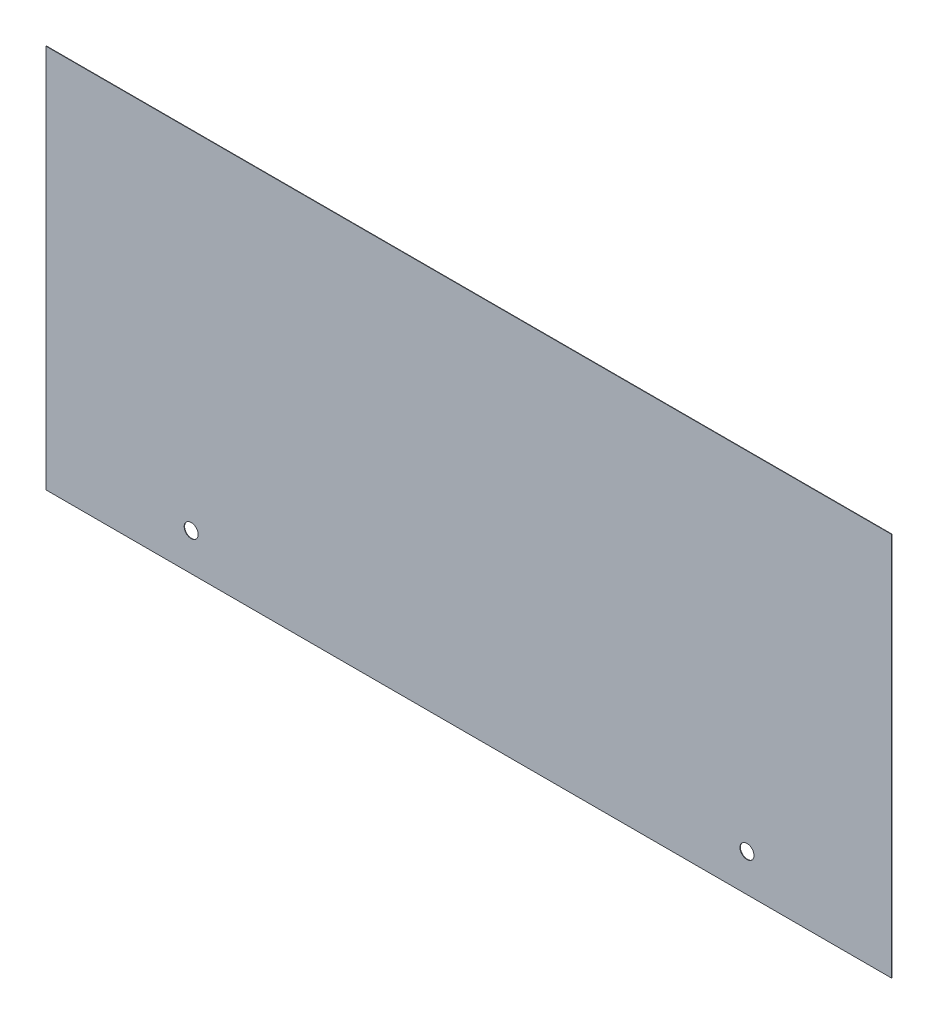
from build123d import *

# Parameters (mm, degrees)
SKETCH1_W           = 502.7676
SKETCH1_H           = 810.1076
BOSS_EXTRUDE1_DEPTH = 0.254
SKETCH2_R           = 4.1656
CUT_EXTRUDE1_DEPTH  = 1.254
SKETCH3_W           = 502.7676
SKETCH3_H           = 581.5076
CUT_EXTRUDE2_DEPTH  = 1.254


with BuildPart() as part:
    # Sketch1 → Boss-Extrude1 (new body)
    with BuildSketch(Plane.XY):
        Rectangle(SKETCH1_W, SKETCH1_H)
    extrude(amount=BOSS_EXTRUDE1_DEPTH)

    # Sketch2 → Cut-Extrude1 (cut, through all)
    with BuildSketch(Plane(origin=(0, 0, 0), x_dir=(-1, 0, 0), z_dir=(0, 0, -1))):
        with Locations((-165.481, 395.1478)):
            Circle(SKETCH2_R)
        with Locations((165.1254, 395.1478)):
            Circle(SKETCH2_R)
        with Locations((165.1254, -382.8288)):
            Circle(SKETCH2_R)
        with Locations((-165.481, -382.8288)):
            Circle(SKETCH2_R)
    extrude(amount=-CUT_EXTRUDE1_DEPTH, mode=Mode.SUBTRACT)

    # Sketch3 → Cut-Extrude2 (cut, through all)
    with BuildSketch(Plane.XY.offset(0.254)):
        with Locations((0, 114.3)):
            Rectangle(SKETCH3_W, SKETCH3_H)
    extrude(amount=-CUT_EXTRUDE2_DEPTH, mode=Mode.SUBTRACT)


solid = part.part
